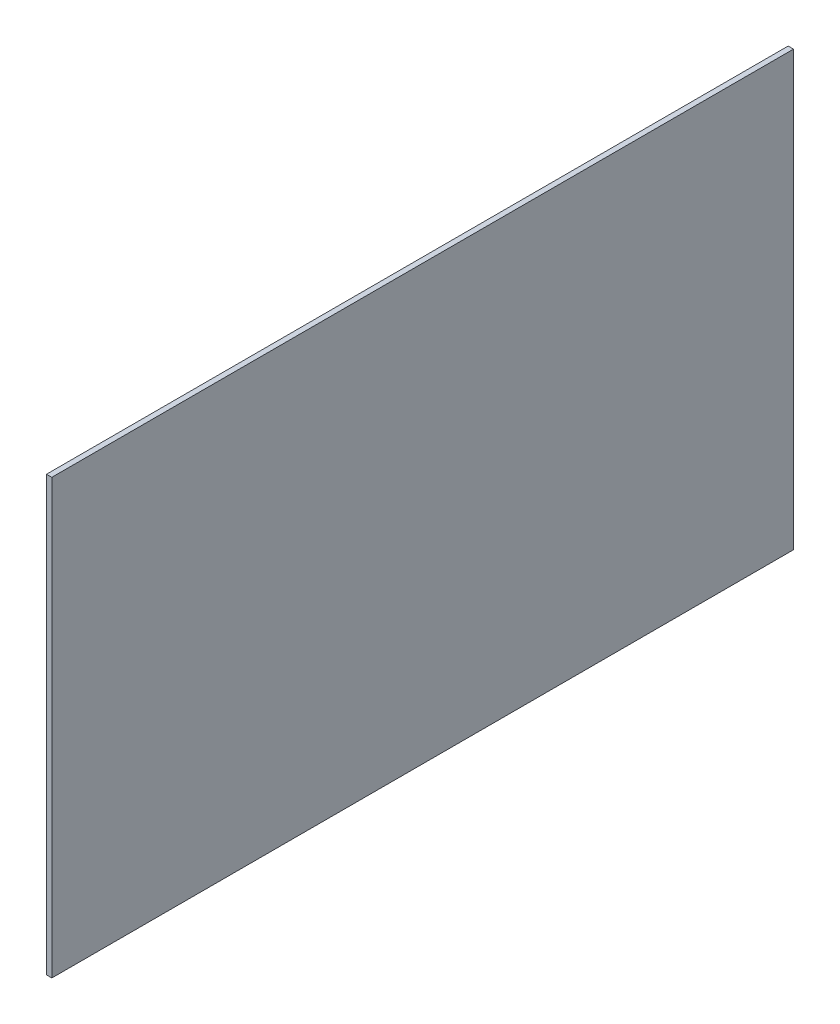
from build123d import *

# Parameters (mm, degrees)
SKIZZE1_W                       = 2222
SKIZZE1_H                       = 1299
AUFSATZ_LINEAR_AUSTRAGEN1_DEPTH = 16


with BuildPart() as part:
    # Skizze1 → Aufsatz-Linear austragen1 (new body)
    with BuildSketch(Plane(origin=(0, 0, 0), x_dir=(0, 0, -1), z_dir=(1, 0, 0))):
        with Locations((-1111, 649.5)):
            Rectangle(SKIZZE1_W, SKIZZE1_H)
    extrude(amount=AUFSATZ_LINEAR_AUSTRAGEN1_DEPTH)


solid = part.part
